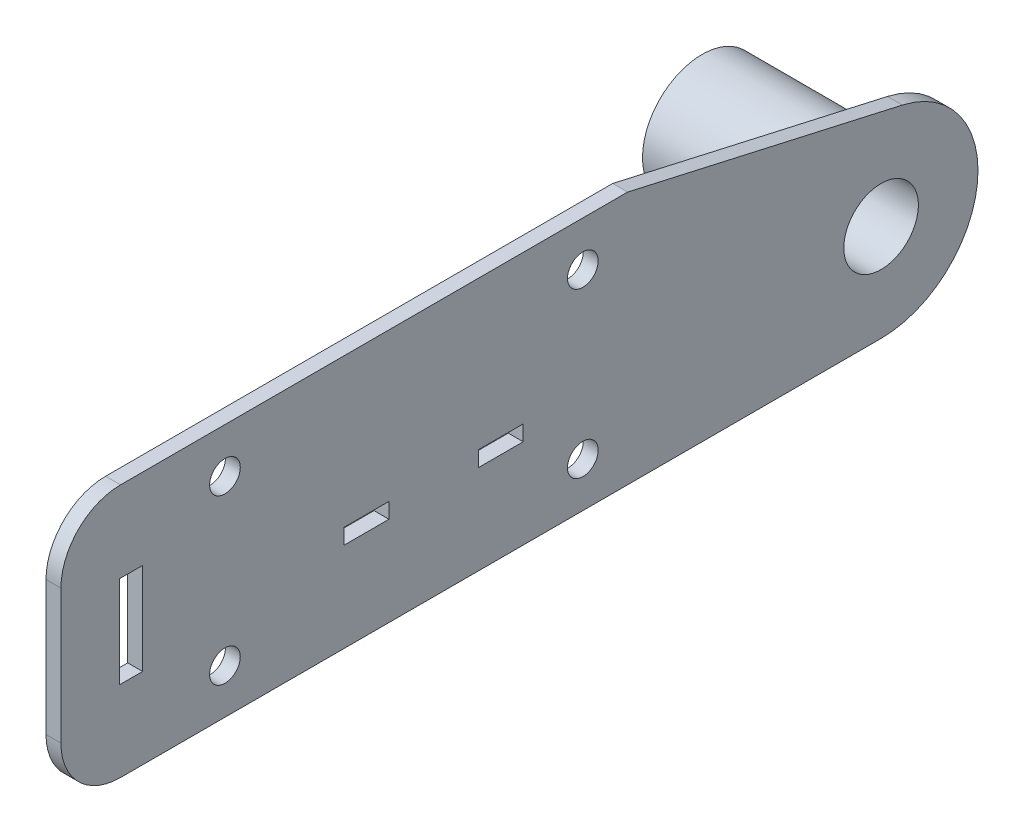
from build123d import *

# Parameters (mm, degrees)
SKETCH1_R                = 3.2639
SKETCH1_R_2              = 12.7
BOSS_EXTRUDE1_DEPTH      = 3.175
SKETCH2_R                = 12.7
SKETCH2_R_2              = 7.9375
BOSS_EXTRUDE2_DEPTH      = 34.925
BOSS_EXTRUDE2_DEPTH_BACK = 3.175
SKETCH4_W                = 4.953
SKETCH4_H                = 19.558
BOSS_EXTRUDE3_DEPTH      = 3.175
SKETCH5_W                = 9.525
SKETCH5_H                = 3.302
CUT_EXTRUDE1_DEPTH       = 39.1


with BuildPart() as part:
    # Sketch1 → Boss-Extrude1 (new body)
    with BuildSketch(Plane(origin=(0, 0, 0), x_dir=(0, 0, -1), z_dir=(1, 0, 0))):
        with BuildLine():
            Line((106.143178695, 13.781217887), (47.625, 26.9875))
            Line((47.625, 26.9875), (-47.625, 26.9875))
            Line((-47.625, 26.9875), (-47.625, -26.9875))
            Line((-47.625, -26.9875), (101.6, -26.9875))
            ThreePointArc((101.6, -26.9875), (122.110538942, -8.635650576), (106.143178695, 13.781217887))
        make_face()
        with Locations((38.1, 17.4625)):
            Circle(SKETCH1_R, mode=Mode.SUBTRACT)
        with Locations((38.1, -17.4625)):
            Circle(SKETCH1_R, mode=Mode.SUBTRACT)
        with Locations((-38.1, -17.4625)):
            Circle(SKETCH1_R, mode=Mode.SUBTRACT)
        with Locations((-38.1, 17.4625)):
            Circle(SKETCH1_R, mode=Mode.SUBTRACT)
        with Locations((101.6, -6.35)):
            Circle(SKETCH1_R_2, mode=Mode.SUBTRACT)
    extrude(amount=BOSS_EXTRUDE1_DEPTH)

    # Sketch2 → Boss-Extrude2 (add, two sides)
    with BuildSketch(Plane.ZY) as boss_extrude2_sk:
        with Locations((-101.6, -6.35)):
            Circle(SKETCH2_R)
        with Locations((-101.6, -6.35)):
            Circle(SKETCH2_R_2, mode=Mode.SUBTRACT)
    extrude(amount=BOSS_EXTRUDE2_DEPTH)
    extrude(boss_extrude2_sk.sketch, amount=-BOSS_EXTRUDE2_DEPTH_BACK)

    # Sketch4 → Boss-Extrude3 (add)
    with BuildSketch(Plane(origin=(3.175, 0, 0), x_dir=(0, 0, -1), z_dir=(1, 0, 0))):
        with BuildLine():
            Line((-47.625, 26.9875), (-60.325, 26.9875))
            ThreePointArc((-60.325, 26.9875), (-69.305256121, 23.267756121), (-73.025, 14.2875))
            Line((-73.025, 14.2875), (-73.025, -14.2875))
            ThreePointArc((-73.025, -14.2875), (-69.305256121, -23.267756121), (-60.325, -26.9875))
            Line((-60.325, -26.9875), (-47.625, -26.9875))
            Line((-47.625, -26.9875), (-47.625, 26.9875))
        make_face()
        with Locations((-58.1025, 0)):
            Rectangle(SKETCH4_W, SKETCH4_H, mode=Mode.SUBTRACT)
    extrude(amount=-BOSS_EXTRUDE3_DEPTH)

    # Sketch5 → Cut-Extrude1 (cut, through all)
    with BuildSketch(Plane(origin=(3.175, 0, 0), x_dir=(0, 0, -1), z_dir=(1, 0, 0))):
        with Locations((20.6375, -6.2865)):
            Rectangle(SKETCH5_W, SKETCH5_H)
        with Locations((-7.9375, -6.2865)):
            Rectangle(SKETCH5_W, SKETCH5_H)
    extrude(amount=-CUT_EXTRUDE1_DEPTH, mode=Mode.SUBTRACT)


solid = part.part
